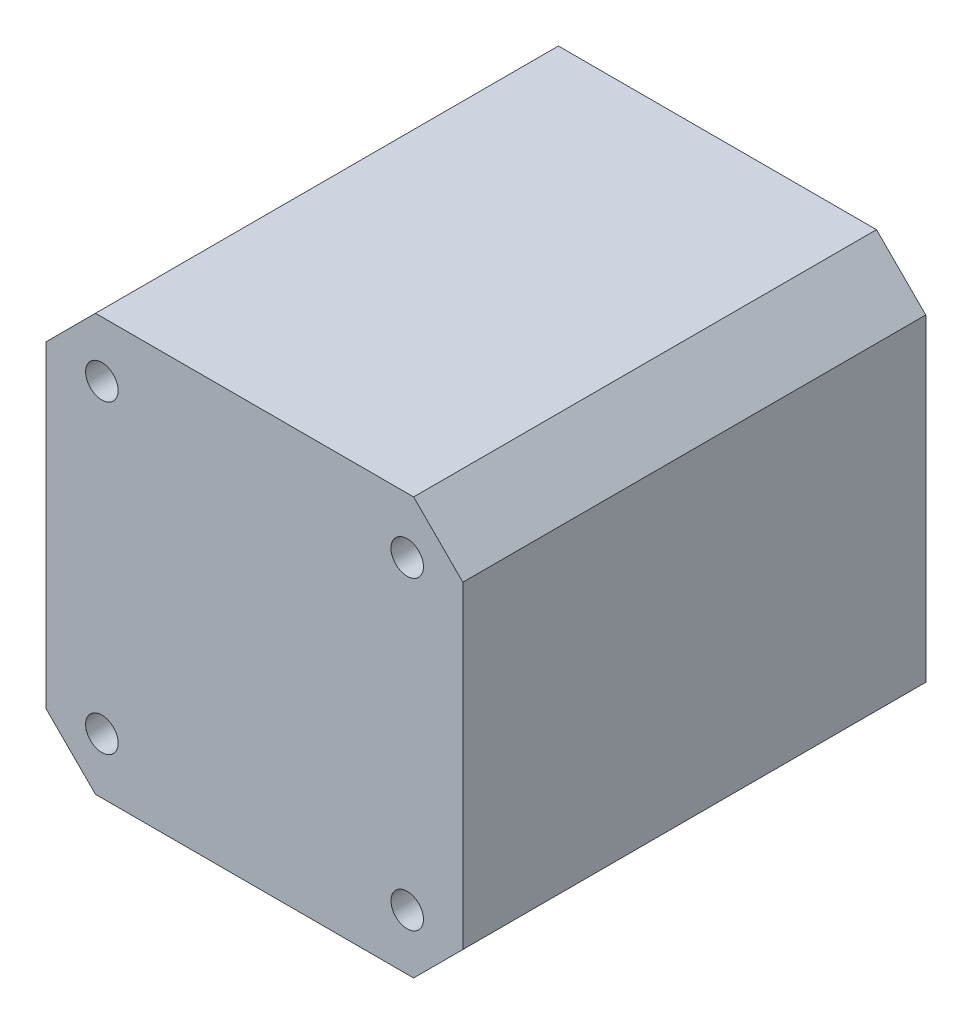
from build123d import *

# Parameters (mm, degrees)
SKETCH_1_R          = 1.65
EXTRUDE_1_DEPTH     = 47
SKETCH_3_R          = 11
EXTRUDE_2_DEPTH     = 2
EXTRUDE_3_DEPTH     = 22
CUT_EXTRUDE_1_DEPTH = 10


with BuildPart() as part:
    # 草图1 → 凸台-拉伸1 (new body)
    with BuildSketch(Plane.XY):
        Polygon((-21.15, 16.15), (-16.15, 21.15), (16.15, 21.15), (21.15, 16.15), (21.15, -16.15), (16.15, -21.15), (-16.15, -21.15), (-21.15, -16.15), align=None)
        with Locations((15.5, 15.5)):
            Circle(SKETCH_1_R, mode=Mode.SUBTRACT)
        with Locations((-15.5, 15.5)):
            Circle(SKETCH_1_R, mode=Mode.SUBTRACT)
        with Locations((15.5, -15.5)):
            Circle(SKETCH_1_R, mode=Mode.SUBTRACT)
        with Locations((-15.5, -15.5)):
            Circle(SKETCH_1_R, mode=Mode.SUBTRACT)
    extrude(amount=EXTRUDE_1_DEPTH)

    # 草图3 → 凸台-拉伸2 (add)
    with BuildSketch(Plane(origin=(0, 0, 0), x_dir=(-1, 0, 0), z_dir=(0, 0, -1))):
        Circle(SKETCH_3_R)
    extrude(amount=EXTRUDE_2_DEPTH)

    # 草图4 → 凸台-拉伸3 (add)
    with BuildSketch(Plane(origin=(0, 0, -2), x_dir=(-1, 0, 0), z_dir=(0, 0, -1))):
        with BuildLine():
            Line((-1.5, 2), (1.5, 2))
            ThreePointArc((1.5, 2), (0, -2.5), (-1.5, 2))
        make_face()
    extrude(amount=EXTRUDE_3_DEPTH)

    # 草图5 → 切除-拉伸1 (cut)
    with BuildSketch(Plane(origin=(0, 0, -24), x_dir=(-1, 0, 0), z_dir=(0, 0, -1))):
        with BuildLine():
            Line((1.5, 2), (-1.5, 2))
            ThreePointArc((-1.5, 2), (0, -2.5), (1.5, 2))
        make_face()
    extrude(amount=-CUT_EXTRUDE_1_DEPTH, mode=Mode.SUBTRACT)


solid = part.part
